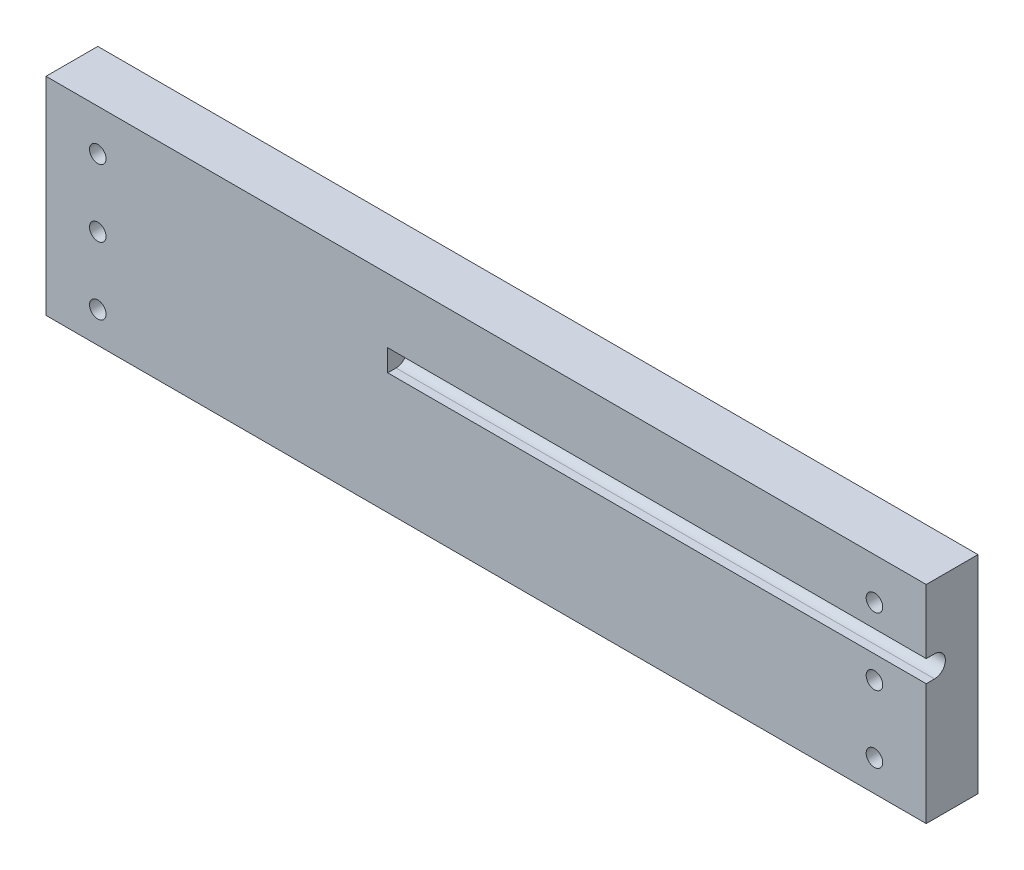
from build123d import *

# Parameters (mm, degrees)
SKETCH1_W                 = 170
SKETCH1_H                 = 40
BOSS_EXTRUDE1_DEPTH       = 10
SKETCH2_R                 = 1.6
CUT_M3_HOLE_DEPTH         = 11
LPATTERN1_COUNT           = 3
LPATTERN1_PITCH           = 13
LPATTERN1_COPY_1_SKETCH_R = 1.6
LPATTERN1_COPY_1_DEPTH    = 11
LPATTERN1_COPY_2_SKETCH_R = 1.6
LPATTERN1_COPY_2_DEPTH    = 11
SKETCH3_R                 = 2.1
CUT_TUBE_SLOT_DEPTH       = 104
SKETCH4_W                 = 1.6
SKETCH4_H                 = 4.2
CUT_EXTRUDE3_DEPTH        = 104


with BuildPart() as part:
    # Sketch1 → Boss-Extrude1 (new body)
    with BuildSketch(Plane.XY):
        with Locations((0, 20)):
            Rectangle(SKETCH1_W, SKETCH1_H)
    extrude(amount=BOSS_EXTRUDE1_DEPTH)

    # Sketch2 → Cut-M3 Hole (cut, through all)
    with BuildSketch(Plane.XY.offset(10)):
        with Locations((-75, 6)):
            Circle(SKETCH2_R)
    cut_m3_hole = extrude(amount=-CUT_M3_HOLE_DEPTH, mode=Mode.SUBTRACT)

    # Mirror1: Cut-M3 Hole across plane
    add(cut_m3_hole.mirror(Plane(origin=(0, 0, 0), x_dir=(0, 0, 1), z_dir=(1, 0, 0))), mode=Mode.SUBTRACT)

    # LPattern1: Cut-M3 Hole ×3
    with Locations(*[(0, i * LPATTERN1_PITCH, 0) for i in range(1, LPATTERN1_COUNT)]):
        add(cut_m3_hole, mode=Mode.SUBTRACT)

    # LPattern1 copy 1 sketch → LPattern1 copy 1 (cut, through all)
    with BuildSketch(Plane(origin=(0, 13, 10), x_dir=(-1, 0, 0), z_dir=(0, 0, 1))):
        with Locations((-75, -6)):
            Circle(LPATTERN1_COPY_1_SKETCH_R)
    extrude(amount=-LPATTERN1_COPY_1_DEPTH, mode=Mode.SUBTRACT)

    # LPattern1 copy 2 sketch → LPattern1 copy 2 (cut, through all)
    with BuildSketch(Plane(origin=(0, 26, 10), x_dir=(-1, 0, 0), z_dir=(0, 0, 1))):
        with Locations((-75, -6)):
            Circle(LPATTERN1_COPY_2_SKETCH_R)
    extrude(amount=-LPATTERN1_COPY_2_DEPTH, mode=Mode.SUBTRACT)

    # Sketch3 → Cut-Tube Slot (cut)
    with BuildSketch(Plane(origin=(85, 0, 0), x_dir=(0, 0, -1), z_dir=(1, 0, 0))):
        with Locations((-8.4, 25.5)):
            Circle(SKETCH3_R)
    extrude(amount=-CUT_TUBE_SLOT_DEPTH, mode=Mode.SUBTRACT)

    # Sketch4 → Cut-Extrude3 (cut)
    with BuildSketch(Plane(origin=(85, 0, 0), x_dir=(0, 0, -1), z_dir=(1, 0, 0))):
        with Locations((-9.2, 25.5)):
            Rectangle(SKETCH4_W, SKETCH4_H)
    extrude(amount=-CUT_EXTRUDE3_DEPTH, mode=Mode.SUBTRACT)


solid = part.part
